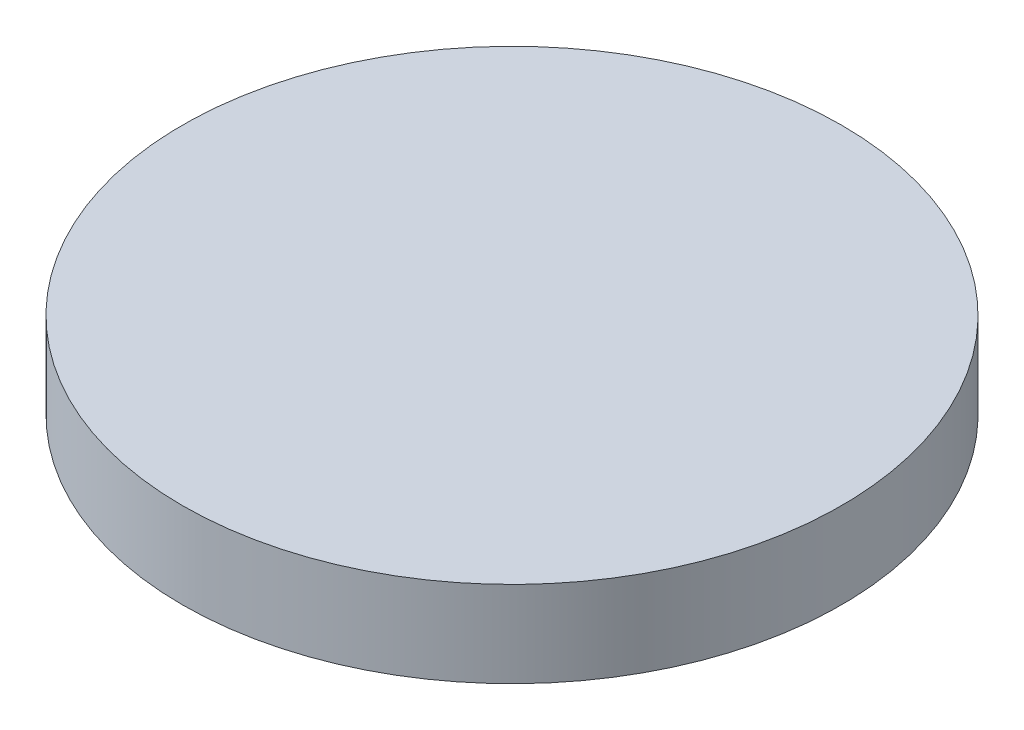
from build123d import *

# Parameters (mm, degrees)
SKETCH1_R           = 11.5
BOSS_EXTRUDE1_DEPTH = 3


with BuildPart() as part:
    # Sketch1 → Boss-Extrude1 (new body)
    with BuildSketch(Plane(origin=(0, 0, 0), x_dir=(1, 0, 0), z_dir=(0, 1, 0))):
        Circle(SKETCH1_R)
    extrude(amount=BOSS_EXTRUDE1_DEPTH)


solid = part.part
